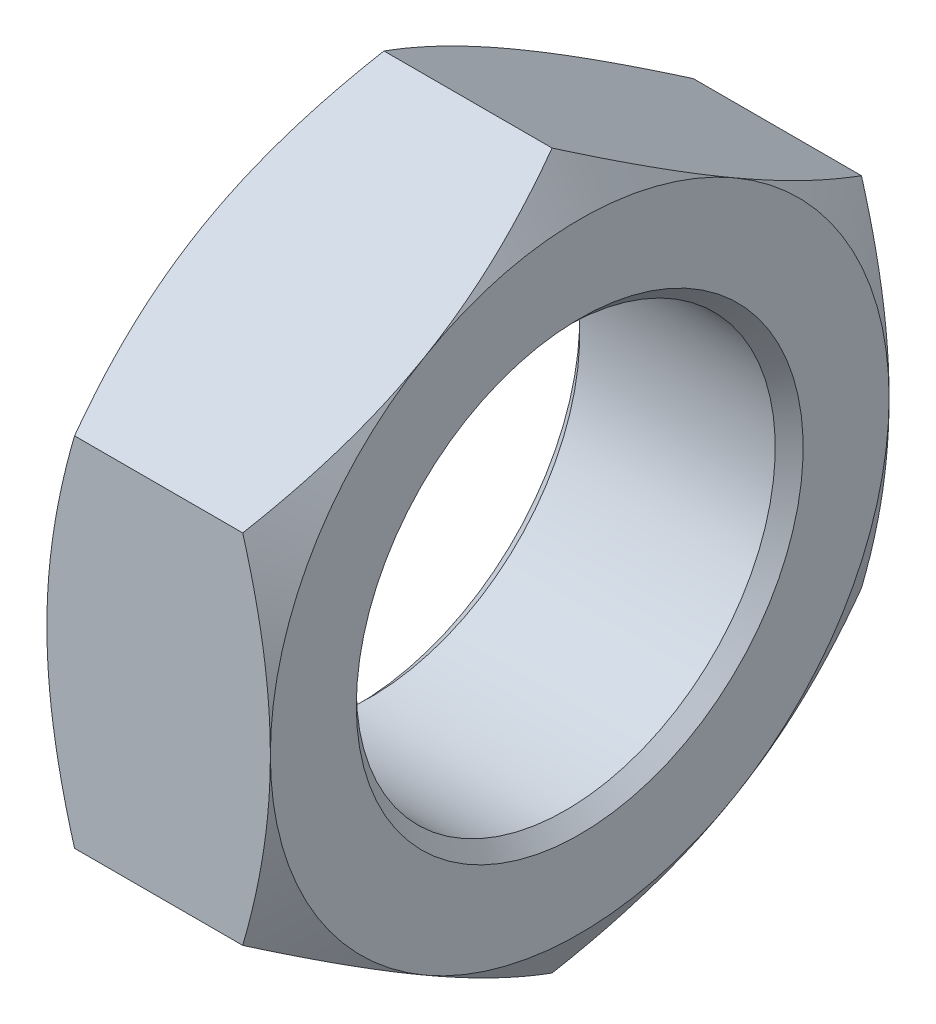
from build123d import *

# Parameters (mm, degrees)
SKETCH_2_W          = 72
SKETCH_2_H          = 72
CUT_EXTRUDE_1_DEPTH = 26


with BuildPart() as part:
    # 草图1 → 旋转1 (revolve)
    with BuildSketch(Plane.XY):
        Polygon((0, 0), (0, 18), (2.078460969, 21.6), (10.921539031, 21.6), (13, 18), (13, 0), align=None)
    revolve(axis=Axis((13, 0, 0), (-1, 0, 0)))

    # 草图2 → 切除-拉伸1 (cut)
    with BuildSketch(Plane(origin=(0, 0, 0), x_dir=(0, 0, -1), z_dir=(1, 0, 0))):
        Rectangle(SKETCH_2_W, SKETCH_2_H)
        Polygon((-18, -10.392304845), (0, -20.784609691), (18, -10.392304845), (18, 10.392304845), (0, 20.784609691), (-18, 10.392304845), align=None, mode=Mode.SUBTRACT)
    extrude(amount=CUT_EXTRUDE_1_DEPTH, mode=Mode.SUBTRACT)

    # 草图3 → 切除-旋转1 (revolve, cut)
    with BuildSketch(Plane.XY):
        Polygon((0, 0), (0, 13), (0.812, 12.188), (12.188, 12.188), (13, 13), (13, 0), align=None)
    revolve(axis=Axis((13, 0, 0), (-1, 0, 0)), mode=Mode.SUBTRACT)


solid = part.part
